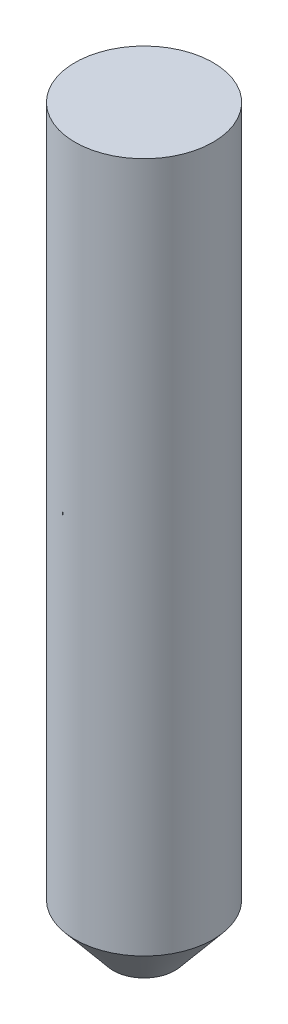
from build123d import *

# Parameters (mm, degrees)
SKETCH1_W      = 15
SKETCH1_H      = 10
SKETCH1_5_W    = 2.5
SKETCH1_5_H    = 130
REVOLVE2_ANGLE = 260


with BuildPart() as part:
    # Sketch1 → Revolve1 (revolve)
    with BuildSketch(Plane.XY):
        with Locations((-7.5, -5)):
            Rectangle(SKETCH1_W, SKETCH1_H)
        Polygon((-12.5, -150), (-12.5, -140), (-15, -140), (-15, -150), (-6.693376137, -160), (-4.693376137, -160), (-4.693376137, -158.5), (-6.335585997, -158.5), align=None)
    revolve(axis=Axis((0, -943.518843805, 0), (0, 1, 0)))

    # Sketch1_5 → Revolve2 (revolve)
    with BuildSketch(Plane.XY):
        with Locations((-13.75, -75)):
            Rectangle(SKETCH1_5_W, SKETCH1_5_H)
    revolve(axis=Axis((0, -943.518843805, 0), (0, 1, 0)), revolution_arc=REVOLVE2_ANGLE)


solid = part.part
